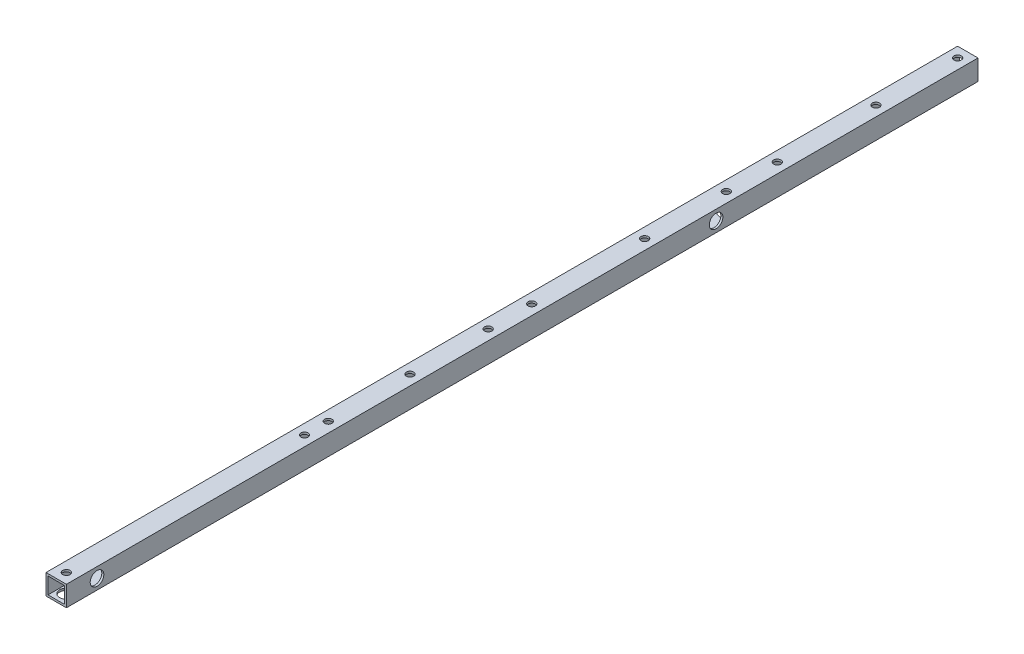
from build123d import *

# Parameters (mm, degrees)
SKETCH_1_W                  = 15
SKETCH_1_H                  = 15
SKETCH_1_W_2                = 12
SKETCH_1_H_2                = 12
EXTRUDE_1_DEPTH             = 670
SKETCH_4_R                  = 2.7
CUT_EXTRUDE_3_DEPTH         = 20
SKETCH_3_R                  = 2.7
CUT_EXTRUDE_4_DEPTH         = 30
SKETCH_5_R                  = 2.7
CUT_EXTRUDE_5_DEPTH         = 40
SKETCH_6_R                  = 5
CUT_EXTRUDE_6_DEPTH         = 10
SKETCH_7_R                  = 5
CUT_EXTRUDE_7_DEPTH         = 10
HOLE_WIZARD_5_4_5_4_1_D     = 5.4
HOLE_WIZARD_10_0_10_1_D     = 10
HOLE_WIZARD_10_0_10_1_DEPTH = 1.5
HOLE_WIZARD_10_0_10_1_TIP   = 3.004303095


with BuildPart() as part:
    # ｽｹｯﾁ1 → ﾎﾞｽ - 押し出し1 (new body)
    with BuildSketch(Plane.XY):
        Rectangle(SKETCH_1_W, SKETCH_1_H)
        Rectangle(SKETCH_1_W_2, SKETCH_1_H_2, mode=Mode.SUBTRACT)
    extrude(amount=EXTRUDE_1_DEPTH)

    # ｽｹｯﾁ4 → ｶｯﾄ - 押し出し3 (cut)
    with BuildSketch(Plane(origin=(7.5, 0, 0), x_dir=(0, 0, -1), z_dir=(1, 0, 0))):
        with Locations((-647.5, 0)):
            Circle(SKETCH_4_R)
        with Locations((-192.5, 0)):
            Circle(SKETCH_4_R)
    extrude(amount=-CUT_EXTRUDE_3_DEPTH, mode=Mode.SUBTRACT)

    # ｽｹｯﾁ3 → ｶｯﾄ - 押し出し4 (cut)
    with BuildSketch(Plane(origin=(0, 7.5, 0), x_dir=(1, 0, 0), z_dir=(0, 1, 0))):
        with Locations((0, -177.5)):
            Circle(SKETCH_3_R)
        with Locations((0, -487.5)):
            Circle(SKETCH_3_R)
        with Locations((0, -352.5)):
            Circle(SKETCH_3_R)
        with Locations((0, -662.5)):
            Circle(SKETCH_3_R)
        with Locations((0, -140)):
            Circle(SKETCH_3_R)
    extrude(amount=-CUT_EXTRUDE_4_DEPTH, mode=Mode.SUBTRACT)

    # ｽｹｯﾁ5 → ｶｯﾄ - 押し出し5 (cut)
    with BuildSketch(Plane(origin=(0, 7.5, 0), x_dir=(1, 0, 0), z_dir=(0, 1, 0))):
        with Locations((0, -7.5)):
            Circle(SKETCH_5_R)
        with Locations((0, -67.5)):
            Circle(SKETCH_5_R)
        with Locations((0, -410)):
            Circle(SKETCH_5_R)
        with Locations((0, -470)):
            Circle(SKETCH_5_R)
    extrude(amount=-CUT_EXTRUDE_5_DEPTH, mode=Mode.SUBTRACT)

    # ｽｹｯﾁ6 → ｶｯﾄ - 押し出し6 (cut)
    with BuildSketch(Plane(origin=(0, -7.5, 0), x_dir=(-1, 0, 0), z_dir=(0, -1, 0))):
        with Locations((0, -662.5)):
            Circle(SKETCH_6_R)
        with Locations((0, -177.5)):
            Circle(SKETCH_6_R)
        with Locations((0, -352.5)):
            Circle(SKETCH_6_R)
        with Locations((0, -487.5)):
            Circle(SKETCH_6_R)
        with Locations((0, -470)):
            Circle(SKETCH_6_R)
        with Locations((0, -410)):
            Circle(SKETCH_6_R)
        with Locations((0, -67.5)):
            Circle(SKETCH_6_R)
        with Locations((0, -7.5)):
            Circle(SKETCH_6_R)
        with Locations((0, -140)):
            Circle(SKETCH_6_R)
    extrude(amount=-CUT_EXTRUDE_6_DEPTH, mode=Mode.SUBTRACT)

    # ｽｹｯﾁ7 → ｶｯﾄ - 押し出し7 (cut)
    with BuildSketch(Plane(origin=(7.5, 0, 0), x_dir=(0, 0, -1), z_dir=(1, 0, 0))):
        with Locations((-647.5, 0)):
            Circle(SKETCH_7_R)
        with Locations((-192.5, 0)):
            Circle(SKETCH_7_R)
    extrude(amount=-CUT_EXTRUDE_7_DEPTH, mode=Mode.SUBTRACT)

    # Ø5.4 (5.4) 直径の穴1 (through all)
    with Locations(Plane(origin=(0, 7.5, 0), x_dir=(1, 0, 0), z_dir=(0, 1, 0))):
        with Locations((0, -237.5), (0, -320.5)):
            Hole(HOLE_WIZARD_5_4_5_4_1_D / 2)

    # Ø10.0 (10) 直径の穴1
    with Locations(Plane(origin=(0, -7.5, 0), x_dir=(-1, 0, 0), z_dir=(0, -1, 0))):
        with Locations((0, -237.5), (0, -320.5)):
            Hole(HOLE_WIZARD_10_0_10_1_D / 2, depth=HOLE_WIZARD_10_0_10_1_DEPTH)
            with Locations((0, 0, -(HOLE_WIZARD_10_0_10_1_DEPTH + HOLE_WIZARD_10_0_10_1_TIP / 2))):  # 118° drill point
                Cone(0, HOLE_WIZARD_10_0_10_1_D / 2, HOLE_WIZARD_10_0_10_1_TIP, mode=Mode.SUBTRACT)


solid = part.part
